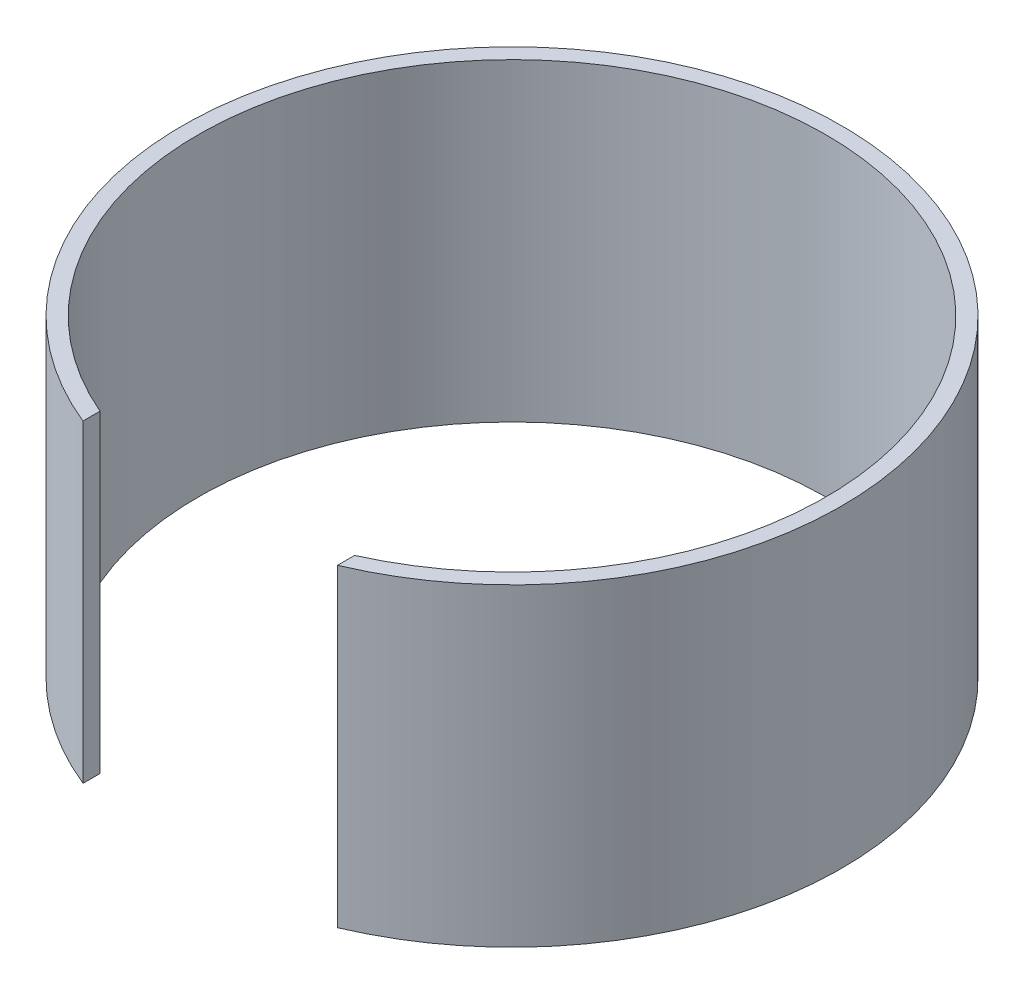
from build123d import *

# Parameters (mm, degrees)
BOSS_EXTRUDE1_DEPTH = 100


with BuildPart() as part:
    # Sketch1 → Boss-Extrude1 (new body)
    with BuildSketch(Plane(origin=(0, 0, 0), x_dir=(1, 0, 0), z_dir=(0, 1, 0))):
        with BuildLine():
            Line((-39.330662506, -97.355528795), (-39.330662506, -91.940736275))
            ThreePointArc((-39.330662506, -91.940736275), (-0.927748641, 99.99569632), (41.02977643, -91.195161308))
            Line((41.02977643, -91.195161308), (41.02977643, -96.651732763))
            ThreePointArc((41.02977643, -96.651732763), (-0.91955383, 104.995973355), (-39.330662506, -97.355528795))
        make_face()
    extrude(amount=BOSS_EXTRUDE1_DEPTH)


solid = part.part
